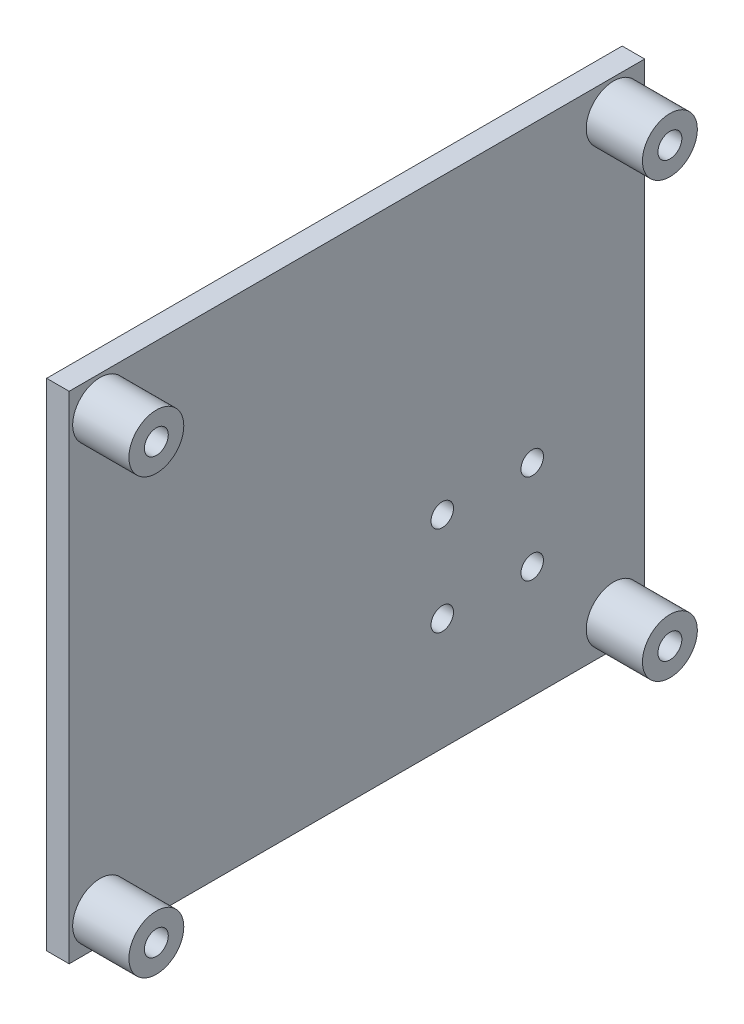
from build123d import *

# Parameters (mm, degrees)
SKETCH1_W           = 65
SKETCH1_H           = 56
BOSS_EXTRUDE1_DEPTH = 2.54
SKETCH2_R           = 3.1
SKETCH2_R_2         = 1.349999967
SKETCH2_R_3         = 1.35
BOSS_EXTRUDE2_DEPTH = 6.35
SKETCH3_R           = 2.54
SKETCH3_R_2         = 1.27
BOSS_EXTRUDE3_DEPTH = 6.35
SKETCH4_R           = 1.349999967
SKETCH4_R_2         = 1.35
SKETCH4_R_3         = 1.27
CUT_EXTRUDE1_DEPTH  = 12.7


with BuildPart() as part:
    # Sketch1 → Boss-Extrude1 (new body)
    with BuildSketch(Plane(origin=(0, 0, 0), x_dir=(0, 0, -1), z_dir=(1, 0, 0))):
        with Locations((-303.603151862, 66.376790831)):
            Rectangle(SKETCH1_W, SKETCH1_H)
    extrude(amount=BOSS_EXTRUDE1_DEPTH)

    # Sketch2 → Boss-Extrude2 (add)
    with BuildSketch(Plane(origin=(2.54, 0, 0), x_dir=(0, 0, -1), z_dir=(1, 0, 0))):
        with Locations((-332.603151862, 90.876790831)):
            Circle(SKETCH2_R)
        with Locations((-332.603151862, 90.876790831)):
            Circle(SKETCH2_R_2, mode=Mode.SUBTRACT)
        with Locations((-274.603151862, 90.876790831)):
            Circle(SKETCH2_R)
        with Locations((-274.603151862, 90.876790831)):
            Circle(SKETCH2_R_3, mode=Mode.SUBTRACT)
        with Locations((-274.603151862, 41.876790831)):
            Circle(SKETCH2_R)
        with Locations((-274.603151862, 41.876790831)):
            Circle(SKETCH2_R_3, mode=Mode.SUBTRACT)
        with Locations((-332.603151862, 41.876790831)):
            Circle(SKETCH2_R)
        with Locations((-332.603151862, 41.876790831)):
            Circle(SKETCH2_R_3, mode=Mode.SUBTRACT)
    extrude(amount=BOSS_EXTRUDE2_DEPTH)

    # Sketch3 → Boss-Extrude3 (add)
    with BuildSketch(Plane.ZY):
        with Locations((283.803151862, 61.236790831)):
            Circle(SKETCH3_R)
        with Locations((283.803151862, 61.236790831)):
            Circle(SKETCH3_R_2, mode=Mode.SUBTRACT)
        with Locations((293.963151862, 61.236790831)):
            Circle(SKETCH3_R)
        with Locations((293.963151862, 61.236790831)):
            Circle(SKETCH3_R_2, mode=Mode.SUBTRACT)
        with Locations((283.803151862, 51.076790831)):
            Circle(SKETCH3_R)
        with Locations((283.803151862, 51.076790831)):
            Circle(SKETCH3_R_2, mode=Mode.SUBTRACT)
        with Locations((293.963151862, 51.076790831)):
            Circle(SKETCH3_R)
        with Locations((293.963151862, 51.076790831)):
            Circle(SKETCH3_R_2, mode=Mode.SUBTRACT)
    extrude(amount=BOSS_EXTRUDE3_DEPTH)

    # Sketch4 → Cut-Extrude1 (cut, symmetric)
    with BuildSketch(Plane(origin=(2.54, 0, 0), x_dir=(0, 0, -1), z_dir=(1, 0, 0))):
        with Locations((-332.603151862, 90.876790831)):
            Circle(SKETCH4_R)
        with Locations((-274.603151862, 90.876790831)):
            Circle(SKETCH4_R_2)
        with Locations((-274.603151862, 41.876790831)):
            Circle(SKETCH4_R_2)
        with Locations((-332.603151862, 41.876790831)):
            Circle(SKETCH4_R_2)
        with Locations((-283.803151862, 61.236790831)):
            Circle(SKETCH4_R_3)
        with Locations((-293.963151862, 61.236790831)):
            Circle(SKETCH4_R_3)
        with Locations((-283.803151862, 51.076790831)):
            Circle(SKETCH4_R_3)
        with Locations((-293.963151862, 51.076790831)):
            Circle(SKETCH4_R_3)
    extrude(amount=CUT_EXTRUDE1_DEPTH, both=True, mode=Mode.SUBTRACT)


solid = part.part
